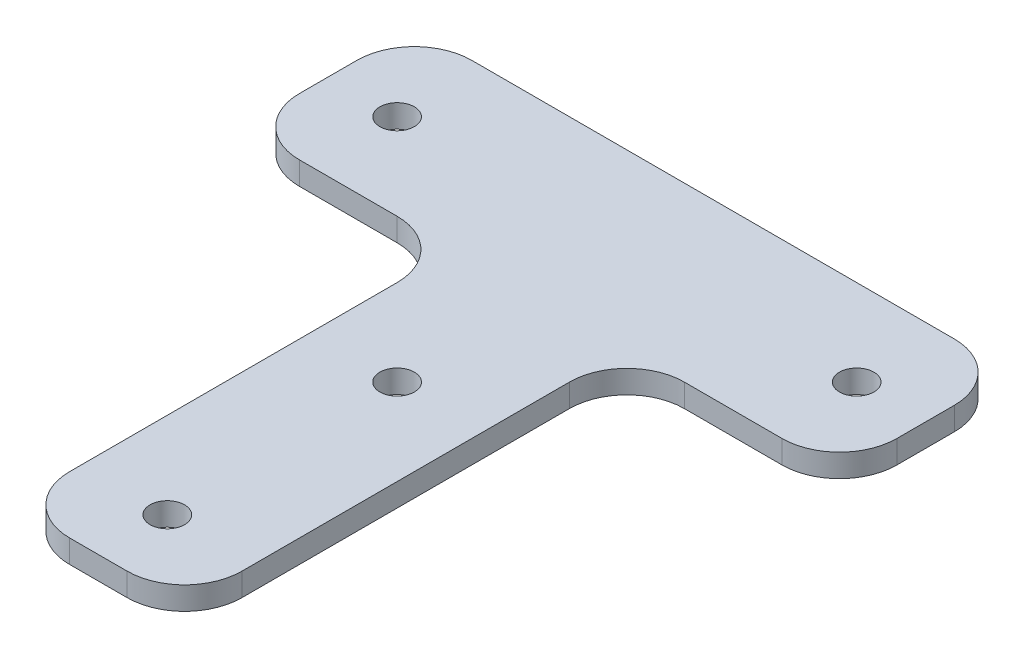
from build123d import *

# Parameters (mm, degrees)
SKETCH1_R           = 1.5
BOSS_EXTRUDE1_DEPTH = 2
FILLET1_R           = 5


with BuildPart() as part:
    # Sketch1 → Boss-Extrude1 (new body)
    with BuildSketch(Plane(origin=(0, 0, 0), x_dir=(1, 0, 0), z_dir=(0, 1, 0))):
        Polygon((7.5, -46), (7.5, -7.5), (26, -7.5), (26, 7.5), (-26, 7.5), (-26, -7.5), (-7.5, -7.5), (-7.5, -46), align=None)
        with Locations((0, -40)):
            Circle(SKETCH1_R, mode=Mode.SUBTRACT)
        with Locations((0, -20)):
            Circle(SKETCH1_R, mode=Mode.SUBTRACT)
        with Locations((20, 0)):
            Circle(SKETCH1_R, mode=Mode.SUBTRACT)
        with Locations((-20, 0)):
            Circle(SKETCH1_R, mode=Mode.SUBTRACT)
    extrude(amount=BOSS_EXTRUDE1_DEPTH)

    # Fillet1
    fillet1_edges = [part.edges().sort_by_distance(p)[0] for p in [
        (-7.5, 1, 46),
        (-7.5, 1, 7.5),
        (-26, 1, 7.5),
        (-26, 1, -7.5),
        (26, 1, -7.5),
        (26, 1, 7.5),
        (7.5, 1, 7.5),
        (7.5, 1, 46),
    ]]
    fillet(fillet1_edges, radius=FILLET1_R)


solid = part.part
